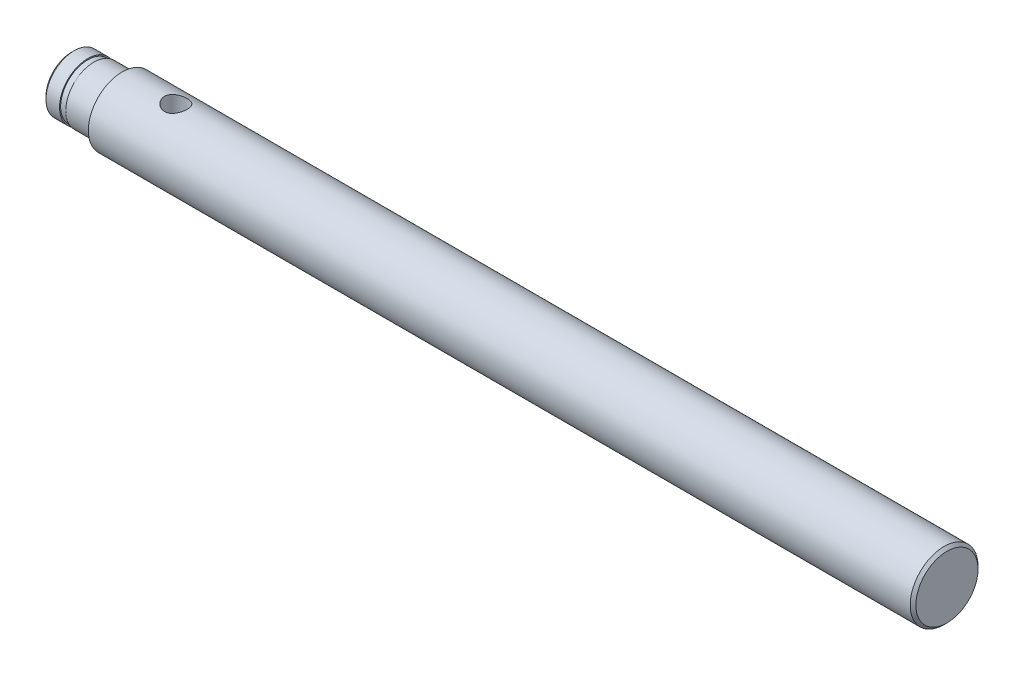
from build123d import *

# Parameters (mm, degrees)
SKETCH1_R           = 6
BOSS_EXTRUDE1_DEPTH = 155
SKETCH3_R           = 2
CUT_EXTRUDE1_DEPTH  = 10
CHAMFER1_SIZE       = 0.5
FILLET1_R           = 0.3


with BuildPart() as part:
    # Sketch1 → Boss-Extrude1 (new body)
    with BuildSketch(Plane(origin=(0, 0, 0), x_dir=(0, 0, -1), z_dir=(1, 0, 0))):
        Circle(SKETCH1_R)
    extrude(amount=BOSS_EXTRUDE1_DEPTH)

    # Sketch2 → Cut-Revolve1 (revolve, cut)
    with BuildSketch(Plane.XY):
        Polygon((0, 5), (0, 6), (9, 6), (9, 5), (4, 5), (4, 4.8), (2.9, 4.8), (2.9, 5), align=None)
    revolve(axis=Axis((155, 0, 0), (-1, 0, 0)), mode=Mode.SUBTRACT)

    # Sketch3 → Cut-Extrude1 (cut, symmetric)
    with BuildSketch(Plane(origin=(0, 0, 0), x_dir=(1, 0, 0), z_dir=(0, 1, 0))):
        with Locations((18.5, 0)):
            Circle(SKETCH3_R)
    extrude(amount=CUT_EXTRUDE1_DEPTH, both=True, mode=Mode.SUBTRACT)

    # Chamfer1
    chamfer1_edges = [part.edges().sort_by_distance(p)[0] for p in [
        (155, 0, 6),
        (0, -5, 0),
    ]]
    chamfer(chamfer1_edges, length=CHAMFER1_SIZE)

    # Fillet1
    fillet1_edges = [part.edges().sort_by_distance(p)[0] for p in [
        (9, -5, 0),
    ]]
    fillet(fillet1_edges, radius=FILLET1_R)


solid = part.part
